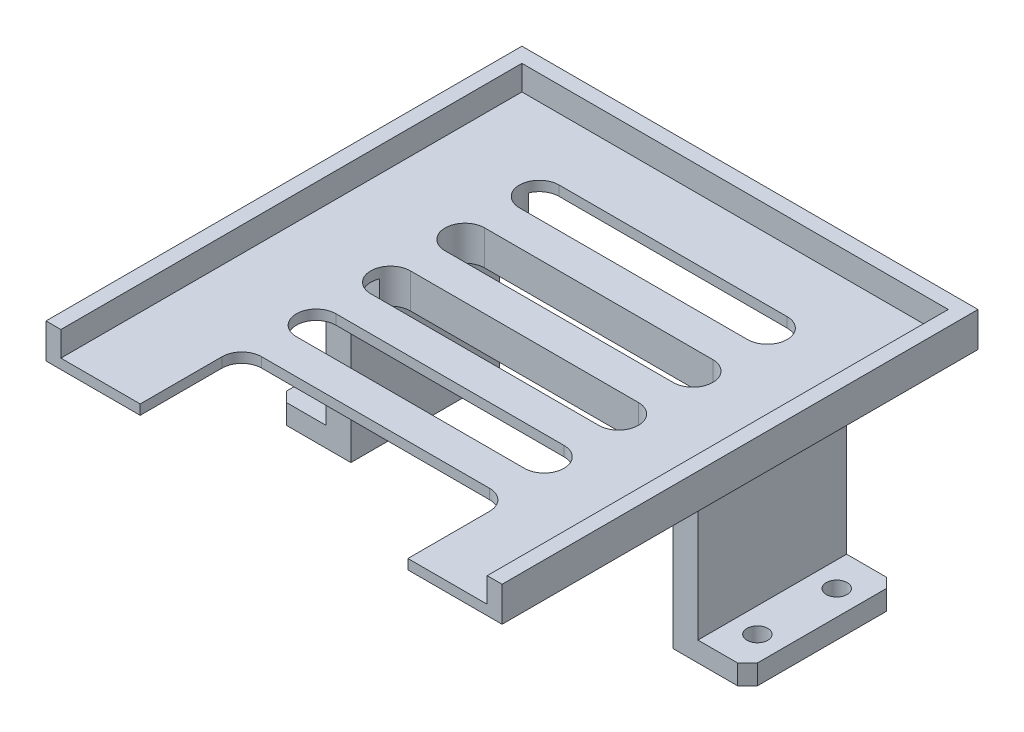
from build123d import *

# Parameters (mm, degrees)
BOSS_EXTRUDE1_DEPTH      = 30
SKETCH2_W                = 50
SKETCH2_H                = 20
CUT_EXTRUDE1_DEPTH       = 30
CHAMFER1_SIZE            = 2
SKETCH3_R                = 2.1
CUT_EXTRUDE2_DEPTH       = 30
SKETCH6_W                = 5
SKETCH6_H                = 30
BOSS_EXTRUDE2_DEPTH      = 5
SKETCH8_W                = 50
SKETCH8_H                = 20
BOSS_EXTRUDE3_DEPTH      = 5
SKETCH9_W                = 25
SKETCH9_H                = 30
BOSS_EXTRUDE4_DEPTH      = 5
SKETCH10_W               = 25
SKETCH10_H               = 30
BOSS_EXTRUDE5_DEPTH      = 5
SKETCH12_W               = 10
SKETCH12_H               = 30
CUT_EXTRUDE3_DEPTH       = 10
SKETCH13_R               = 2.1
CUT_EXTRUDE4_DEPTH       = 10
CHAMFER2_SIZE            = 2
SKETCH14_W               = 6.64500098
SKETCH14_H               = 11.940236137
SKETCH14_W_2             = 7.060313542
SKETCH14_H_2             = 8.410079366
BOSS_EXTRUDE6_DEPTH      = 5
SKETCH15_R               = 2.1
CUT_EXTRUDE5_DEPTH       = 5
SKETCH17_W               = 86
SKETCH17_H               = 93
SKETCH17_W_2             = 71
SKETCH17_H_2             = 30
BOSS_EXTRUDE7_DEPTH      = 2
BOSS_EXTRUDE8_DEPTH      = 5
BOSS_EXTRUDE8_DEPTH_BACK = 2
CUT_EXTRUDE7_DEPTH       = 18
CUT_EXTRUDE8_DEPTH       = 1
SKETCH22_W               = 54
SKETCH22_H               = 16.5
CUT_EXTRUDE9_DEPTH       = 10


with BuildPart() as part:
    # Sketch1 → Boss-Extrude1 (new body)
    with BuildSketch(Plane.XY):
        Polygon((-57.5, -17.5), (-37.5, -17.5), (-32.5, -17.5), (-32.5, 12.5), (32.5, 12.5), (32.5, -17.5), (37.5, -17.5), (57.5, -17.5), (57.5, -12.5), (37.5, -12.5), (37.5, 17.5), (-37.5, 17.5), (-37.5, -12.5), (-57.5, -12.5), align=None)
    extrude(amount=BOSS_EXTRUDE1_DEPTH)

    # Sketch2 → Cut-Extrude1 (cut)
    with BuildSketch(Plane(origin=(0, 17.5, 0), x_dir=(1, 0, 0), z_dir=(0, 1, 0))):
        with Locations((0, -15)):
            Rectangle(SKETCH2_W, SKETCH2_H)
    extrude(amount=-CUT_EXTRUDE1_DEPTH, mode=Mode.SUBTRACT)

    # Chamfer1
    chamfer1_edges = [part.edges().sort_by_distance(p)[0] for p in [
        (-37.5, 17.5, 15),
        (37.5, 17.5, 15),
    ]]
    chamfer(chamfer1_edges, length=CHAMFER1_SIZE)

    # Sketch3 → Cut-Extrude2 (cut)
    with BuildSketch(Plane(origin=(0, -12.5, 0), x_dir=(1, 0, 0), z_dir=(0, 1, 0))):
        with Locations((-47.5, -15)):
            Circle(SKETCH3_R)
        with Locations((47.5, -15)):
            Circle(SKETCH3_R)
    extrude(amount=-CUT_EXTRUDE2_DEPTH, mode=Mode.SUBTRACT)

    # Sketch6 → Boss-Extrude2 (add)
    with BuildSketch(Plane(origin=(0, 17.5, 0), x_dir=(1, 0, 0), z_dir=(0, 1, 0))):
        with Locations((0, -15)):
            Rectangle(SKETCH6_W, SKETCH6_H)
    extrude(amount=-BOSS_EXTRUDE2_DEPTH)

    # Sketch8 → Boss-Extrude3 (add)
    with BuildSketch(Plane(origin=(0, 17.5, 0), x_dir=(1, 0, 0), z_dir=(0, 1, 0))):
        with Locations((0, -15)):
            Rectangle(SKETCH8_W, SKETCH8_H)
    extrude(amount=-BOSS_EXTRUDE3_DEPTH)

    # Sketch9 → Boss-Extrude4 (add)
    with BuildSketch(Plane(origin=(0, -17.5, 0), x_dir=(-1, 0, 0), z_dir=(0, -1, 0))):
        with Locations((45, -15)):
            Rectangle(SKETCH9_W, SKETCH9_H)
    extrude(amount=-BOSS_EXTRUDE4_DEPTH)

    # Sketch10 → Boss-Extrude5 (add)
    with BuildSketch(Plane(origin=(0, -17.5, 0), x_dir=(-1, 0, 0), z_dir=(0, -1, 0))):
        with Locations((-45, -15)):
            Rectangle(SKETCH10_W, SKETCH10_H)
    extrude(amount=-BOSS_EXTRUDE5_DEPTH)

    # Sketch12 → Cut-Extrude3 (cut)
    with BuildSketch(Plane(origin=(0, -12.5, 0), x_dir=(1, 0, 0), z_dir=(0, 1, 0))):
        with Locations((52.5, -15)):
            Rectangle(SKETCH12_W, SKETCH12_H)
        with Locations((-52.5, -15)):
            Rectangle(SKETCH12_W, SKETCH12_H)
    extrude(amount=-CUT_EXTRUDE3_DEPTH, mode=Mode.SUBTRACT)

    # Sketch13 → Cut-Extrude4 (cut)
    with BuildSketch(Plane(origin=(0, -12.5, 0), x_dir=(1, 0, 0), z_dir=(0, 1, 0))):
        with Locations((-42.5, -15)):
            Circle(SKETCH13_R)
        with Locations((42.5, -15)):
            Circle(SKETCH13_R)
    extrude(amount=-CUT_EXTRUDE4_DEPTH, mode=Mode.SUBTRACT)

    # Chamfer2
    chamfer2_edges = [part.edges().sort_by_distance(p)[0] for p in [
        (47.5, -15, 0),
        (-47.5, -15, 0),
        (-47.5, -15, 30),
        (47.5, -15, 30),
    ]]
    chamfer(chamfer2_edges, length=CHAMFER2_SIZE)

    # Sketch14 → Boss-Extrude6 (add)
    with BuildSketch(Plane(origin=(0, -12.5, 0), x_dir=(1, 0, 0), z_dir=(0, 1, 0))):
        with Locations((42.569537531, -14.480859299)):
            Rectangle(SKETCH14_W, SKETCH14_H)
        with Locations((-42.25805311, -15)):
            Rectangle(SKETCH14_W_2, SKETCH14_H_2)
    extrude(amount=-BOSS_EXTRUDE6_DEPTH)

    # Sketch15 → Cut-Extrude5 (cut)
    with BuildSketch(Plane(origin=(0, -12.5, 0), x_dir=(1, 0, 0), z_dir=(0, 1, 0))):
        with Locations((-42.5, -7)):
            Circle(SKETCH15_R)
        with Locations((-42.5, -23)):
            Circle(SKETCH15_R)
        with Locations((42.5, -23)):
            Circle(SKETCH15_R)
        with Locations((42.5, -7)):
            Circle(SKETCH15_R)
    extrude(amount=-CUT_EXTRUDE5_DEPTH, mode=Mode.SUBTRACT)

    # Sketch17 → Boss-Extrude7 (add)
    with BuildSketch(Plane(origin=(0, 17.5, 0), x_dir=(1, 0, 0), z_dir=(0, 1, 0))):
        with Locations((0, -31.5)):
            Rectangle(SKETCH17_W, SKETCH17_H)
        with Locations((0, -15)):
            Rectangle(SKETCH17_W_2, SKETCH17_H_2, mode=Mode.SUBTRACT)
        with Locations((0, -15)):
            Rectangle(SKETCH17_W_2, SKETCH17_H_2)
    extrude(amount=BOSS_EXTRUDE7_DEPTH)

    # Sketch18 → Boss-Extrude8 (add, two sides)
    with BuildSketch(Plane(origin=(0, 19.5, 0), x_dir=(1, 0, 0), z_dir=(0, 1, 0))) as boss_extrude8_sk:
        Polygon((-46, 18), (-46, -78), (-43, -78), (-43, 15), (43, 15), (43, -78), (46, -78), (46, 18), align=None)
    extrude(amount=BOSS_EXTRUDE8_DEPTH)
    extrude(boss_extrude8_sk.sketch, amount=-BOSS_EXTRUDE8_DEPTH_BACK)

    # Sketch19 → Cut-Extrude7 (cut)
    with BuildSketch(Plane(origin=(0, 19.5, 0), x_dir=(1, 0, 0), z_dir=(0, 1, 0))):
        with BuildLine():
            Line((-23, 2.5), (23, 2.5))
            ThreePointArc((23, 2.5), (27, -1.5), (23, -5.5))
            Line((23, -5.5), (-23, -5.5))
            ThreePointArc((-23, -5.5), (-27, -1.5), (-23, 2.5))
        make_face()
        with BuildLine():
            Line((-23, -12.5), (23, -12.5))
            ThreePointArc((23, -12.5), (27, -16.5), (23, -20.5))
            Line((23, -20.5), (-23, -20.5))
            ThreePointArc((-23, -20.5), (-27, -16.5), (-23, -12.5))
        make_face()
        with BuildLine():
            Line((-23, -27.5), (23, -27.5))
            ThreePointArc((23, -27.5), (27, -31.5), (23, -35.5))
            Line((23, -35.5), (-23, -35.5))
            ThreePointArc((-23, -35.5), (-27, -31.5), (-23, -27.5))
        make_face()
        with BuildLine():
            Line((-23, -50.5), (23, -50.5))
            ThreePointArc((23, -50.5), (27, -46.5), (23, -42.5))
            Line((23, -42.5), (-23, -42.5))
            ThreePointArc((-23, -42.5), (-27, -46.5), (-23, -50.5))
        make_face()
        with BuildLine():
            Line((-23, -65.5), (23, -65.5))
            ThreePointArc((23, -65.5), (27, -61.5), (23, -57.5))
            Line((23, -57.5), (-23, -57.5))
            ThreePointArc((-23, -57.5), (-27, -61.5), (-23, -65.5))
        make_face()
    extrude(amount=-CUT_EXTRUDE7_DEPTH, mode=Mode.SUBTRACT)

    # Sketch21 → Cut-Extrude8 (cut)
    with BuildSketch(Plane(origin=(0, -12.5, 0), x_dir=(1, 0, 0), z_dir=(0, 1, 0))):
        Polygon((-37.5, 0), (-37.5, -30), (-45.5, -30), (-47.5, -28), (-47.5, -2), (-45.5, 0), align=None)
        Polygon((37.5, 0), (37.5, -30), (45.5, -30), (47.5, -28), (47.5, -2), (45.5, 0), align=None)
    extrude(amount=-CUT_EXTRUDE8_DEPTH, mode=Mode.SUBTRACT)

    # Sketch22 → Cut-Extrude9 (cut)
    with BuildSketch(Plane(origin=(0, 19.5, 0), x_dir=(1, 0, 0), z_dir=(0, 1, 0))):
        with Locations((0, -69.75)):
            Rectangle(SKETCH22_W, SKETCH22_H)
    extrude(amount=-CUT_EXTRUDE9_DEPTH, mode=Mode.SUBTRACT)


solid = part.part
